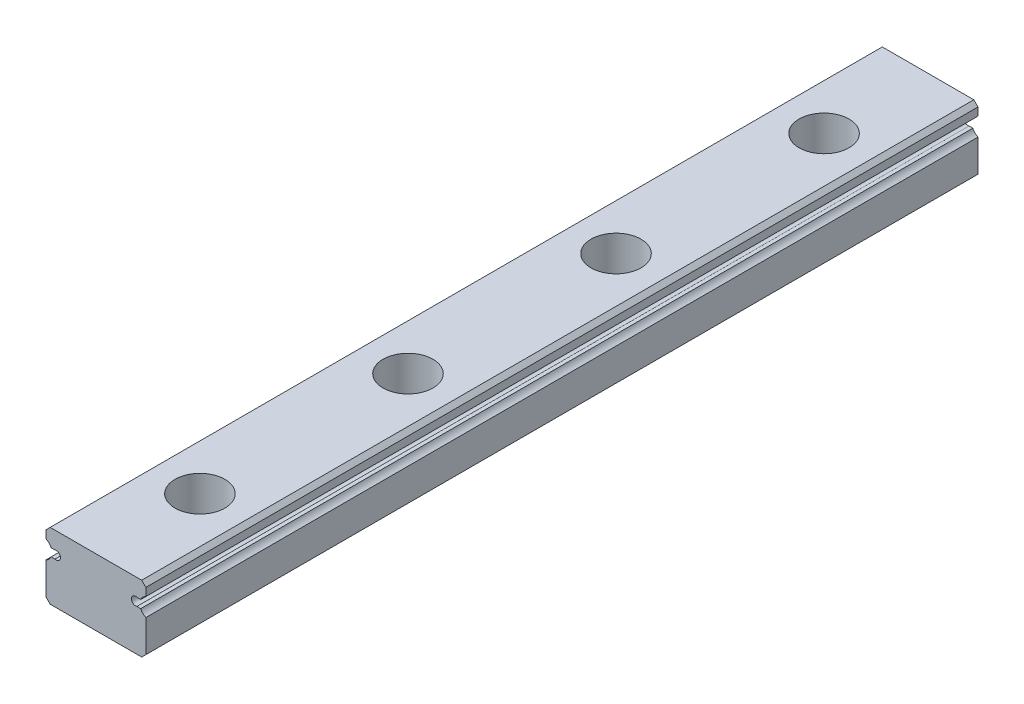
from build123d import *

# Parameters (mm, degrees)
BOSS_EXTRUDE1_DEPTH = 100
SKETCH2_R           = 3
CUT_EXTRUDE1_DEPTH  = 4.5
SKETCH3_R           = 1.75
CUT_EXTRUDE2_DEPTH  = 4.5
LPATTERN1_COUNT     = 4
LPATTERN1_PITCH     = 25


with BuildPart() as part:
    # Sketch1 → Boss-Extrude1 (new body)
    with BuildSketch(Plane.XY):
        with BuildLine():
            Line((6, -3.5), (6, 0.368911094))
            ThreePointArc((6, 0.368911094), (5.63354293, 0.61854293), (5.383911094, 0.985))
            Line((5.383911094, 0.985), (4.92112495, 0.985))
            ThreePointArc((4.92112495, 0.985), (4.265, 1.46), (4.92112495, 1.935))
            Line((4.92112495, 1.935), (5.383911094, 1.935))
            ThreePointArc((5.383911094, 1.935), (5.63354293, 2.30145707), (6, 2.551088906))
            Line((6, 2.551088906), (6, 3.5))
            Line((6, 3.5), (5.5, 4))
            Line((5.5, 4), (-5.5, 4))
            Line((-5.5, 4), (-6, 3.5))
            Line((-6, 3.5), (-6, 2.551088906))
            ThreePointArc((-6, 2.551088906), (-5.63354293, 2.30145707), (-5.383911094, 1.935))
            Line((-5.383911094, 1.935), (-4.92112495, 1.935))
            ThreePointArc((-4.92112495, 1.935), (-4.265, 1.46), (-4.92112495, 0.985))
            Line((-4.92112495, 0.985), (-5.383911094, 0.985))
            ThreePointArc((-5.383911094, 0.985), (-5.63354293, 0.61854293), (-6, 0.368911094))
            Line((-6, 0.368911094), (-6, -3.5))
            Line((-6, -3.5), (-5.5, -4))
            Line((-5.5, -4), (5.5, -4))
            Line((5.5, -4), (6, -3.5))
        make_face()
    extrude(amount=BOSS_EXTRUDE1_DEPTH)

    # Sketch2 → Cut-Extrude1 (cut)
    with BuildSketch(Plane(origin=(0, 4, 0), x_dir=(1, 0, 0), z_dir=(0, 1, 0))):
        with Locations((0, -12.5)):
            Circle(SKETCH2_R)
    cut_extrude1 = extrude(amount=-CUT_EXTRUDE1_DEPTH, mode=Mode.SUBTRACT)

    # Sketch3 → Cut-Extrude2 (cut, through all)
    with BuildSketch(Plane(origin=(0, -0.5, 0), x_dir=(1, 0, 0), z_dir=(0, 1, 0))):
        with Locations((0, -12.5)):
            Circle(SKETCH3_R)
    cut_extrude2 = extrude(amount=-CUT_EXTRUDE2_DEPTH, mode=Mode.SUBTRACT)

    # LPattern1: Cut-Extrude1, Cut-Extrude2 ×4
    with Locations(*[(0, 0, i * LPATTERN1_PITCH) for i in range(1, LPATTERN1_COUNT)]):
        add(cut_extrude1, mode=Mode.SUBTRACT)
        add(cut_extrude2, mode=Mode.SUBTRACT)


solid = part.part
